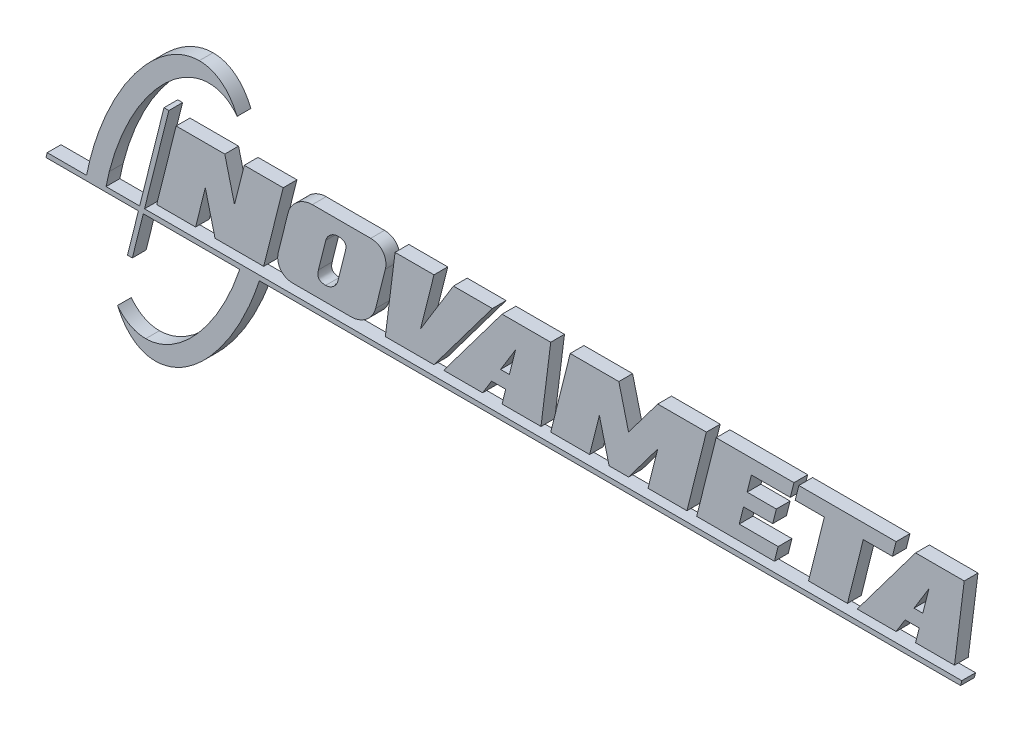
from build123d import *

# Parameters (mm, degrees)
BOSS_EXTRUDE1_DEPTH   = 3
BOSS_EXTRUDE1_2_DEPTH = 3
BOSS_EXTRUDE1_3_DEPTH = 3
BOSS_EXTRUDE1_4_DEPTH = 3
BOSS_EXTRUDE1_5_DEPTH = 3
BOSS_EXTRUDE1_6_DEPTH = 3
BOSS_EXTRUDE1_7_DEPTH = 3
BOSS_EXTRUDE1_8_DEPTH = 3
BOSS_EXTRUDE1_9_DEPTH = 3


with BuildPart() as part:
    # Model → Boss-Extrude1 (new body)
    with BuildSketch(Plane.XY):
        Polygon((190.468994093, 147.279210033), (192.423741271, 150.456793853), (195.502278597, 150.458171892), (194.707495069, 147.279210033), (203.183463491, 147.278521014), (205.304264272, 164.232524916), (194.708528597, 164.232524916), (181.990614104, 147.278521014), align=None)
        Polygon((196.295339578, 153.635583458), (194.372287278, 153.635583458), (197.622045849, 158.934484824), align=None, mode=Mode.SUBTRACT)
    extrude(amount=BOSS_EXTRUDE1_DEPTH)


with BuildPart() as body_2:
    # Model → Boss-Extrude1 2 (new body)
    with BuildSketch(Plane.XY):
        Polygon((171.395911958, 147.279899052), (179.872913909, 147.279210033), (183.316631356, 161.053218547), (189.675244093, 161.053907566), (190.469683112, 164.232524916), (169.277522744, 164.232524916), (168.482739216, 161.053907566), (174.840662934, 161.053907566), align=None)
    extrude(amount=BOSS_EXTRUDE1_2_DEPTH)


with BuildPart() as body_3:
    # Model → Boss-Extrude1 3 (new body)
    with BuildSketch(Plane.XY):
        Polygon((147.024961986, 147.279210033), (151.264841, 164.232524916), (168.218155882, 164.232524916), (167.423372354, 161.053907566), (158.945681384, 161.053218547), (158.018261679, 157.344401002), (164.376874416, 157.344401002), (163.586914022, 154.183698149), (157.228301284, 154.183698149), (156.296402956, 150.456793853), (164.774093926, 150.458171892), (163.978276869, 147.278521014), align=None)
    extrude(amount=BOSS_EXTRUDE1_3_DEPTH)


with BuildPart() as body_4:
    # Model → Boss-Extrude1 4 (new body)
    with BuildSketch(Plane.XY):
        Polygon((149.145418257, 164.232524916), (138.549682583, 164.232524916), (132.191414355, 155.755695219), (130.073025141, 164.232524916), (119.476255938, 164.232524916), (115.237754963, 147.279210033), (123.713723385, 147.279210033), (125.834524166, 155.75535071), (127.95256887, 147.278521014), (132.190380826, 147.278521014), (138.549682583, 155.75535071), (136.428881802, 147.279210033), (144.905539243, 147.279210033), align=None)
    extrude(amount=BOSS_EXTRUDE1_4_DEPTH)


with BuildPart() as body_5:
    # Model → Boss-Extrude1 5 (new body)
    with BuildSketch(Plane.XY):
        Polygon((100.402829293, 147.279210033), (102.35861, 150.456793853), (105.436458307, 150.458171892), (104.641330269, 147.279210033), (113.117643201, 147.278521014), (115.238788491, 164.232524916), (104.642708307, 164.232524916), (91.926171852, 147.278521014), align=None)
        Polygon((106.230552816, 153.635583458), (104.307156007, 153.635583458), (107.556570069, 158.934484824), align=None, mode=Mode.SUBTRACT)
    extrude(amount=BOSS_EXTRUDE1_5_DEPTH)


with BuildPart() as body_6:
    # Model → Boss-Extrude1 6 (new body)
    with BuildSketch(Plane.XY):
        Polygon((89.807438129, 147.279210033), (79.211013435, 147.279210033), (81.331469706, 164.232524916), (89.807782638, 164.232524916), (86.893576367, 152.576561106), (94.046628123, 164.232524916), (102.523630074, 164.232524916), align=None)
    extrude(amount=BOSS_EXTRUDE1_6_DEPTH)


with BuildPart() as body_7:
    # Model → Boss-Extrude1 7 (new body)
    with BuildSketch(Plane.XY):
        Polygon((29.409402119, 147.278521014), (37.88640407, 147.278521014), (40.006515832, 155.75535071), (42.124560536, 147.278521014), (52.72064072, 147.278521014), (56.960519734, 164.232524916), (48.484206802, 164.232524916), (46.363750531, 155.75535071), (44.245361317, 164.232524916), (33.648936624, 164.232524916), align=None)
    extrude(amount=BOSS_EXTRUDE1_7_DEPTH)


with BuildPart() as body_8:
    # Model → Boss-Extrude1 8 (new body)
    with BuildSketch(Plane.XY):
        with BuildLine():
            Line((76.033257359, 164.232524916), (63.318098943, 164.232524916))
            add(Edge.make_bspline(
                [(63.318098943, 164.232524916), (60.976812051, 164.232524916), (58.605552828, 162.334794067), (58.019197577, 159.993851685)],
                knots=[1, 1, 1, 1, 2, 2, 2, 2], degree=3))
            Line((58.019197577, 159.993851685), (55.899774834, 151.516849734))
            add(Edge.make_bspline(
                [(55.899774834, 151.516849734), (55.314453111, 149.176596371), (56.737622056, 147.279210033), (59.078564438, 147.279210033)],
                knots=[3, 3, 3, 3, 4, 4, 4, 4], degree=3))
            Line((59.078564438, 147.279210033), (71.793722855, 147.279210033))
            add(Edge.make_bspline(
                [(71.793722855, 147.279210033), (74.134320728, 147.279210033), (76.50592446, 149.176596371), (77.092279712, 151.516849734)],
                knots=[5, 5, 5, 5, 6, 6, 6, 6], degree=3))
            Line((77.092279712, 151.516849734), (79.211702454, 159.993851685))
            add(Edge.make_bspline(
                [(79.211702454, 159.993851685), (79.797368687, 162.334794067), (78.374199742, 164.232524916), (76.033257359, 164.232524916)],
                knots=[7, 7, 7, 7, 8, 8, 8, 8], degree=3))
        make_face()
        with BuildLine():
            Line((64.642393647, 152.577594634), (66.231960704, 158.934484824))
            add(Edge.make_bspline(
                [(66.231960704, 158.934484824), (66.52479382, 160.104956015), (67.710251177, 161.053563057), (68.880894623, 161.053563057)],
                knots=[2, 2, 2, 2, 3, 3, 3, 3], degree=3))
            add(Edge.make_bspline(
                [(68.880894623, 161.053563057), (70.867681189, 161.053563057), (70.763294796, 160.105989543), (70.47011717, 158.935173843)],
                knots=[3, 3, 3, 3, 4, 4, 4, 4], degree=3))
            Line((70.47011717, 158.935173843), (68.880205603, 152.577250125))
            add(Edge.make_bspline(
                [(68.880205603, 152.577250125), (68.588061506, 151.406606679), (67.401570621, 150.457482873), (66.231616194, 150.457482873)],
                knots=[5, 5, 5, 5, 6, 6, 6, 6], degree=3))
            add(Edge.make_bspline(
                [(66.231616194, 150.457482873), (64.51010198, 150.457482873), (64.348527002, 151.40591766), (64.642393647, 152.577594634)],
                knots=[0, 0, 0, 0, 1, 1, 1, 1], degree=3))
        make_face(mode=Mode.SUBTRACT)
    extrude(amount=BOSS_EXTRUDE1_8_DEPTH)


with BuildPart() as body_9:
    # Model → Boss-Extrude1 9 (new body)
    with BuildSketch(Plane.XY):
        with BuildLine():
            Line((204.509480743, 144.100764938), (204.774064076, 145.160476309))
            Line((204.774064076, 145.160476309), (26.76081271, 145.160476309))
            Line((26.76081271, 145.160476309), (32.060403095, 166.351947658))
            Line((32.060403095, 166.351947658), (31.000347214, 166.351947658))
            Line((31.000347214, 166.351947658), (25.701445849, 145.160476309))
            Line((25.701445849, 145.160476309), (18.384752057, 145.160476309))
            add(Edge.make_bspline(
                [(18.384752057, 145.160476309), (18.58077799, 146.202962203), (18.811599388, 147.263362593), (19.080316836, 148.33806013)],
                knots=[6, 6, 6, 6, 7, 7, 7, 7], degree=3))
            add(Edge.make_bspline(
                [(19.080316836, 148.33806013), (22.885769309, 163.55366885), (32.612307392, 175.887455197), (40.804055437, 175.887455197)],
                knots=[7, 7, 7, 7, 8, 8, 8, 8], degree=3))
            add(Edge.make_bspline(
                [(40.804055437, 175.887455197), (43.313118479, 175.887455197), (45.386032432, 174.730075369), (46.947349706, 172.688511784)],
                knots=[8, 8, 8, 8, 9, 9, 9, 9], degree=3))
            add(Edge.make_bspline(
                [(46.947349706, 172.688511784), (45.219289811, 176.686889604), (42.397067589, 179.066761565), (38.686355242, 179.066761565)],
                knots=[9, 9, 9, 9, 10, 10, 10, 10], degree=3))
            add(Edge.make_bspline(
                [(38.686355242, 179.066761565), (29.762179897, 179.066761565), (19.086518007, 165.308772745), (14.842849389, 148.33840464)],
                knots=[10, 10, 10, 10, 11, 11, 11, 11], degree=3))
            add(Edge.make_bspline(
                [(14.842849389, 148.33840464), (14.57447645, 147.265429651), (14.33848741, 146.20502926), (14.134193247, 145.161165328)],
                knots=[11, 11, 11, 11, 12, 12, 12, 12], degree=3))
            Line((14.134193247, 145.161165328), (5.569685871, 145.161165328))
            Line((5.569685871, 145.161165328), (5.304413519, 144.100764938))
            Line((5.304413519, 144.100764938), (25.436173496, 144.100764938))
            Line((25.436173496, 144.100764938), (23.051478401, 134.564051616))
            Line((23.051478401, 134.564051616), (24.110845263, 134.564051616))
            Line((24.110845263, 134.564051616), (26.495884868, 144.100764938))
            Line((26.495884868, 144.100764938), (47.511656347, 144.100764938))
            add(Edge.make_bspline(
                [(47.511656347, 144.100764938), (43.111580393, 130.901915115), (34.441308585, 120.798139076), (27.025396044, 120.798139076)],
                knots=[19, 19, 19, 19, 20, 20, 20, 20], degree=3))
            add(Edge.make_bspline(
                [(27.025396044, 120.798139076), (24.518400059, 120.798139076), (22.446519634, 121.955691159), (20.885891379, 123.994498667)],
                knots=[20, 20, 20, 20, 21, 21, 21, 21], degree=3))
            add(Edge.make_bspline(
                [(20.885891379, 123.994498667), (22.613606765, 119.998187904), (25.435484477, 117.619693981), (29.144474277, 117.619693981)],
                knots=[21, 21, 21, 21, 22, 22, 22, 22], degree=3))
            add(Edge.make_bspline(
                [(29.144474277, 117.619693981), (37.311417634, 117.619693981), (46.943215592, 129.140093284), (51.771861424, 144.100764938)],
                knots=[22, 22, 22, 22, 23, 23, 23, 23], degree=3))
            Line((51.771861424, 144.100764938), (204.509480743, 144.100764938))
        make_face()
    extrude(amount=BOSS_EXTRUDE1_9_DEPTH)


solid = Compound([part.part, body_2.part, body_3.part, body_4.part, body_5.part, body_6.part, body_7.part, body_8.part, body_9.part])
